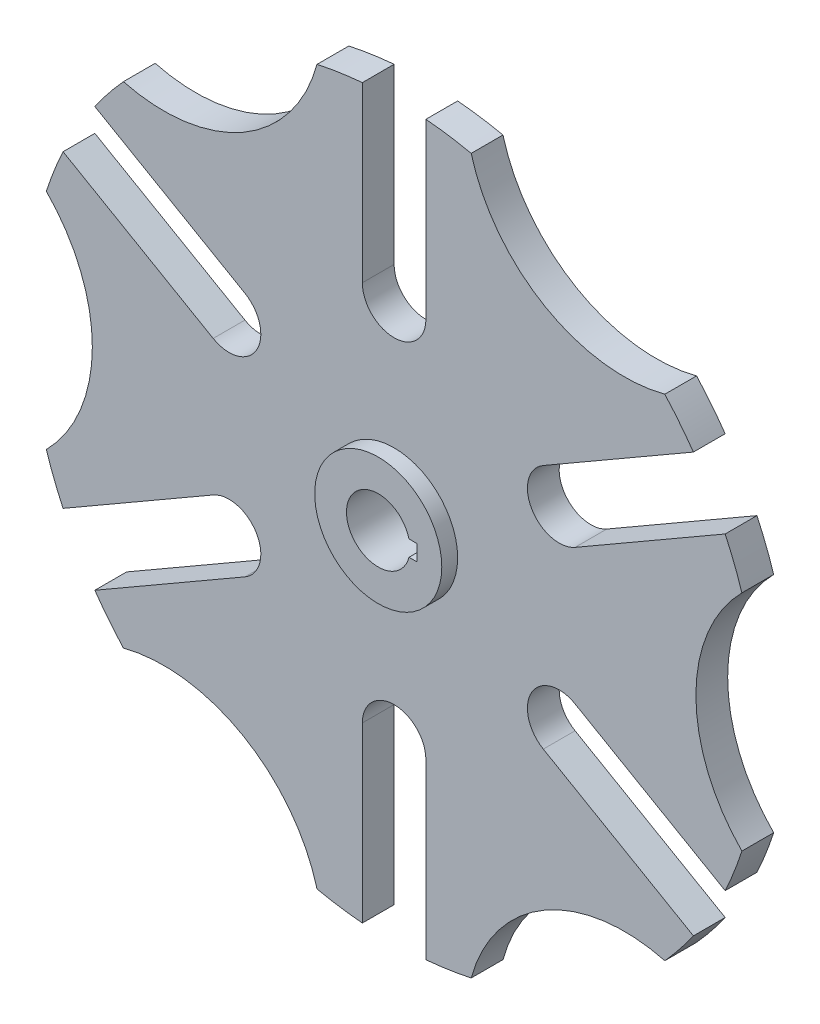
from build123d import *

# Parameters (mm, degrees)
SKETCH3_R           = 73.025
BOSS_EXTRUDE2_DEPTH = 3.175
SKETCH5_R           = 31.75
CUT_EXTRUDE3_DEPTH  = 104.467984179
CUT_EXTRUDE4_DEPTH  = 101.826071922
BOSS_EXTRUDE4_START = 3.175
SKETCH7_3_R         = 12.7
BOSS_EXTRUDE4_DEPTH = 3.175


with BuildPart() as part:
    # Sketch3 → Boss-Extrude2 (new, symmetric)
    with BuildSketch(Plane.XY):
        Circle(SKETCH3_R)
    extrude(amount=BOSS_EXTRUDE2_DEPTH, both=True)

    # Sketch5 → Cut-Extrude3 (cut, through all)
    with BuildSketch(Plane.XY.offset(3.175)):
        with Locations((92.075, 0)):
            Circle(SKETCH5_R)
        with Locations((46.0375, -79.739289053)):
            Circle(SKETCH5_R)
        with Locations((-46.0375, -79.739289053)):
            Circle(SKETCH5_R)
        with Locations((-92.075, 0)):
            Circle(SKETCH5_R)
        with Locations((-46.0375, 79.739289053)):
            Circle(SKETCH5_R)
        with Locations((46.0375, 79.739289053)):
            Circle(SKETCH5_R)
        with BuildLine():
            Line((66.176953095, 30.874933265), (36.170567884, 13.550738686))
            ThreePointArc((36.170567884, 13.550738686), (27.49630657, 15.875), (29.820567884, 24.549261314))
            Line((29.820567884, 24.549261314), (59.826953095, 41.873455893))
            ThreePointArc((59.826953095, 41.873455893), (68.501214409, 39.549194579), (66.176953095, 30.874933265))
        make_face()
        with BuildLine():
            Line((59.826953095, -41.873455893), (29.820567884, -24.549261314))
            ThreePointArc((29.820567884, -24.549261314), (27.49630657, -15.875), (36.170567884, -13.550738686))
            Line((36.170567884, -13.550738686), (66.176953095, -30.874933265))
            ThreePointArc((66.176953095, -30.874933265), (68.501214409, -39.549194579), (59.826953095, -41.873455893))
        make_face()
        with BuildLine():
            Line((-6.35, -72.748389157), (-6.35, -38.1))
            ThreePointArc((-6.35, -38.1), (0, -31.75), (6.35, -38.1))
            Line((6.35, -38.1), (6.35, -72.748389157))
            ThreePointArc((6.35, -72.748389157), (0, -79.098389157), (-6.35, -72.748389157))
        make_face()
        with BuildLine():
            Line((-66.176953095, -30.874933265), (-36.170567884, -13.550738686))
            ThreePointArc((-36.170567884, -13.550738686), (-27.49630657, -15.875), (-29.820567884, -24.549261314))
            Line((-29.820567884, -24.549261314), (-59.826953095, -41.873455893))
            ThreePointArc((-59.826953095, -41.873455893), (-68.501214409, -39.549194579), (-66.176953095, -30.874933265))
        make_face()
        with BuildLine():
            Line((-59.826953095, 41.873455893), (-29.820567884, 24.549261314))
            ThreePointArc((-29.820567884, 24.549261314), (-27.49630657, 15.875), (-36.170567884, 13.550738686))
            Line((-36.170567884, 13.550738686), (-66.176953095, 30.874933265))
            ThreePointArc((-66.176953095, 30.874933265), (-68.501214409, 39.549194579), (-59.826953095, 41.873455893))
        make_face()
        with BuildLine():
            Line((6.35, 72.748389157), (6.35, 38.1))
            ThreePointArc((6.35, 38.1), (0, 31.75), (-6.35, 38.1))
            Line((-6.35, 38.1), (-6.35, 72.748389157))
            ThreePointArc((-6.35, 72.748389157), (0, 79.098389157), (6.35, 72.748389157))
        make_face()
    extrude(amount=-CUT_EXTRUDE3_DEPTH, mode=Mode.SUBTRACT)

    # Sketch7 → Cut-Extrude4 (cut, through all)
    with BuildSketch(Plane.XY.offset(3.175)):
        with BuildLine():
            Line((6.148361062, 1.5875), (7.735861062, 1.5875))
            Line((7.735861062, 1.5875), (7.735861062, -1.5875))
            Line((7.735861062, -1.5875), (6.148361062, -1.5875))
            ThreePointArc((6.148361062, -1.5875), (-6.35, 0), (6.148361062, 1.5875))
        make_face()
    extrude(amount=-CUT_EXTRUDE4_DEPTH, mode=Mode.SUBTRACT)

    # Sketch7_3 → Boss-Extrude4 (add)
    with BuildSketch(Plane.XY.offset(3.175).offset(BOSS_EXTRUDE4_START)):
        Circle(SKETCH7_3_R)
        with BuildLine():
            Line((6.148361062, 1.5875), (7.735861062, 1.5875))
            Line((7.735861062, 1.5875), (7.735861062, -1.5875))
            Line((7.735861062, -1.5875), (6.148361062, -1.5875))
            ThreePointArc((6.148361062, -1.5875), (-6.35, 0), (6.148361062, 1.5875))
        make_face(mode=Mode.SUBTRACT)
    extrude(amount=-BOSS_EXTRUDE4_DEPTH)


solid = part.part
